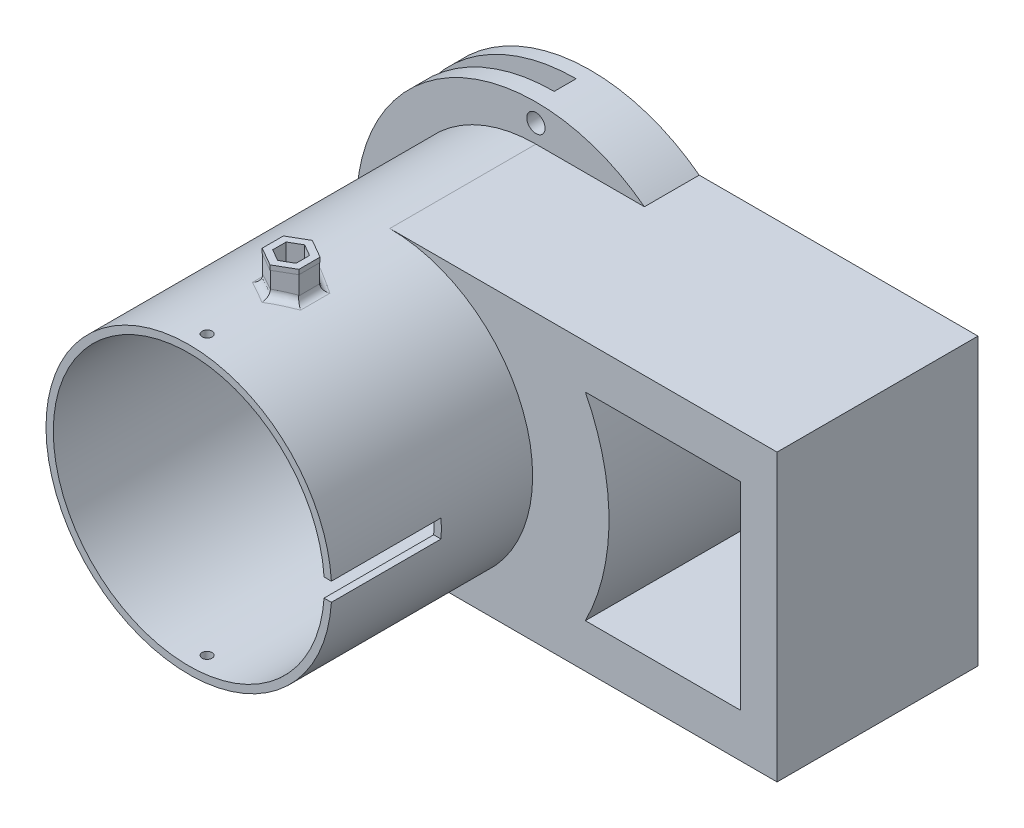
from build123d import *

# Parameters (mm, degrees)
SKETCH1_R                  = 49.657
SKETCH1_R_2                = 47.117
BOSS_EXTRUDE1_DEPTH        = 69.85
SKETCH2_R                  = 62.357
SKETCH2_R_2                = 49.657
BOSS_EXTRUDE2_DEPTH        = 19.05
F_1_4_0_2500_DOWEL_HOLE1_D = 6.35
SKETCH10_W                 = 38.1
SKETCH10_H                 = 6.35
CUT_EXTRUDE1_DEPTH         = 63.357
SKETCH12_R                 = 3.175
CUT_EXTRUDE3_DEPTH         = 63.357
CUT_EXTRUDE4_REACH         = 64.357
SKETCH14_R                 = 3.429
SKETCH14_R_2               = 3.175
CUT_EXTRUDE5_REACH         = 64.357
SKETCH15_R                 = 1.905
BOSS_EXTRUDE4_START        = 49.022
BOSS_EXTRUDE4_DEPTH        = 8.89
FILLET3_R                  = 2.54
BOSS_EXTRUDE5_DEPTH        = 1.6256
SKETCH18_W                 = 134.62
SKETCH18_H                 = 2.54
BOSS_EXTRUDE6_DEPTH        = 69.85
CUT_EXTRUDE6_START         = -5.08
SKETCH20_R                 = 59.5376
CUT_EXTRUDE6_DEPTH         = 7.62
CUT_EXTRUDE7_REACH         = 64.357
SKETCH21_W                 = 7.62
SKETCH21_H                 = 124.968
BOSS_EXTRUDE7_DEPTH        = 50.8
BOSS_EXTRUDE8_DEPTH        = 69.85


with BuildPart() as part:
    # Sketch1 → Boss-Extrude1 (new body, symmetric)
    with BuildSketch(Plane.XY):
        Circle(SKETCH1_R)
        Circle(SKETCH1_R_2, mode=Mode.SUBTRACT)
    extrude(amount=BOSS_EXTRUDE1_DEPTH, both=True)

    # Sketch2 → Boss-Extrude2 (add)
    with BuildSketch(Plane(origin=(0, 0, -69.85), x_dir=(-1, 0, 0), z_dir=(0, 0, -1))):
        Circle(SKETCH2_R)
        Circle(SKETCH2_R_2, mode=Mode.SUBTRACT)
    extrude(amount=-BOSS_EXTRUDE2_DEPTH)

    # Sketch5 → #8-32 Tapped Hole1 (revolve, cut)
    with BuildSketch(Plane(origin=(0, 0, 63.5), x_dir=(0, 0, -1), z_dir=(1, 0, 0))):
        Polygon((0, 0), (0, 62.357), (1.7272, 62.357), (1.7272, 0.9906), (2.7178, 0), align=None)
    f_8_32_tapped_hole1 = revolve(axis=Axis((0, -6.35, 63.5), (0, 1, 0)), mode=Mode.SUBTRACT)

    # Mirror1: #8-32 Tapped Hole1 across plane
    add(f_8_32_tapped_hole1.mirror(Plane.ZX), mode=Mode.SUBTRACT)

    # 1/4 (0.2500) Dowel Hole1 (through all)
    with Locations(Plane.XY.offset(-50.8)):
        with Locations((-56.007, 0), (0, 56.007), (56.007, 0), (0, -56.007)):
            Hole(F_1_4_0_2500_DOWEL_HOLE1_D / 2)

    # Sketch10 → Cut-Extrude1 (cut, through all)
    with BuildSketch(Plane(origin=(0, 0, 0), x_dir=(0, 0, -1), z_dir=(1, 0, 0))):
        with Locations((-50.8, 0)):
            Rectangle(SKETCH10_W, SKETCH10_H)
    extrude(amount=CUT_EXTRUDE1_DEPTH, mode=Mode.SUBTRACT)

    # Sketch12 → Cut-Extrude3 (cut, through all)
    with BuildSketch(Plane(origin=(0, 0, 0), x_dir=(0, 0, -1), z_dir=(1, 0, 0))):
        Circle(SKETCH12_R)
    extrude(amount=-CUT_EXTRUDE3_DEPTH, mode=Mode.SUBTRACT)

    # Sketch14 → Cut-Extrude4 (cut, up to next)
    with BuildSketch(Plane(origin=(0, 0, 0), x_dir=(0, 0, -1), z_dir=(1, 0, 0)), mode=Mode.PRIVATE) as cut_extrude4_sk1:
        Circle(SKETCH14_R)
        Circle(SKETCH14_R_2, mode=Mode.SUBTRACT)
    cut_extrude4_tool1 = extrude(cut_extrude4_sk1.sketch, amount=-CUT_EXTRUDE4_REACH, mode=Mode.PRIVATE) & part.part
    add(cut_extrude4_tool1.solids().sort_by_distance((0, 0, 3.332013))[0], mode=Mode.SUBTRACT)

    # Sketch15 → Cut-Extrude5 (cut, up to next)
    with BuildSketch(Plane(origin=(0, 0, 0), x_dir=(1, 0, 0), z_dir=(0, 1, 0)), mode=Mode.PRIVATE) as cut_extrude5_sk1:
        with Locations((0, -34.29)):
            Circle(SKETCH15_R)
    cut_extrude5_tool1 = extrude(cut_extrude5_sk1.sketch, amount=CUT_EXTRUDE5_REACH, mode=Mode.PRIVATE) & part.part
    add(cut_extrude5_tool1.solids().sort_by_distance((0, 0, 34.29))[0], mode=Mode.SUBTRACT)

    # Sketch16 → Boss-Extrude4 (add)
    with BuildSketch(Plane(origin=(0, 0, 0), x_dir=(1, 0, 0), z_dir=(0, 1, 0)).offset(BOSS_EXTRUDE4_START)):
        Polygon((-6.263704526, -30.673648506), (-6.263704526, -37.906351494), (0, -41.522702988), (6.263704526, -37.906351494), (6.263704526, -30.673648506), (0, -27.057297012), align=None)
        Polygon((0, -29.597297012), (-4.064, -31.943648506), (-4.064, -36.636351494), (0, -38.982702988), (4.064, -36.636351494), (4.064, -31.943648506), align=None, mode=Mode.SUBTRACT)
    extrude(amount=BOSS_EXTRUDE4_DEPTH)

    # Fillet3
    fillet3_edges = [part.edges().sort_by_distance(p)[0] for p in [
        (-3.136562658, 49.557841193, 28.868192307),
        (3.136562658, 49.557841193, 28.868192307),
        (6.263704526, 49.260365961, 34.29),
        (3.136562658, 49.557841193, 39.711807693),
        (-3.136562658, 49.557841193, 39.711807693),
        (-6.263704526, 49.260365961, 34.29),
    ]]
    fillet(fillet3_edges, radius=FILLET3_R)

    # Sketch17 → Boss-Extrude5 (add)
    with BuildSketch(Plane(origin=(0, 57.912, 0), x_dir=(1, 0, 0), z_dir=(0, 1, 0))):
        Polygon((-6.374687849, -37.970427746), (0, -41.650855491), (6.374687849, -37.970427746), (6.374687849, -30.609572254), (0, -26.929144509), (-6.374687849, -30.609572254), align=None)
        Polygon((-4.064, -36.636351494), (0, -38.982702988), (4.064, -36.636351494), (4.064, -31.943648506), (0, -29.597297012), (-4.064, -31.943648506), align=None, mode=Mode.SUBTRACT)
    extrude(amount=BOSS_EXTRUDE5_DEPTH)

    # Sketch18 → Boss-Extrude6 (add, through all)
    with BuildSketch(Plane.XY):
        with Locations((67.31, -48.387)):
            Rectangle(SKETCH18_W, SKETCH18_H)
        with Locations((67.31, 48.387)):
            Rectangle(SKETCH18_W, SKETCH18_H)
    extrude(amount=-BOSS_EXTRUDE6_DEPTH)

    # Sketch20 → Cut-Extrude6 (cut)
    with BuildSketch(Plane(origin=(0, 0, -69.85), x_dir=(-1, 0, 0), z_dir=(0, 0, -1)).offset(CUT_EXTRUDE6_START)):
        Circle(SKETCH20_R)
    extrude(amount=-CUT_EXTRUDE6_DEPTH, mode=Mode.SUBTRACT)

    # Sketch21 → Cut-Extrude7 (cut, up to next)
    with BuildSketch(Plane(origin=(0, 0, 0), x_dir=(0, 0, -1), z_dir=(1, 0, 0)), mode=Mode.PRIVATE) as cut_extrude7_sk1:
        with Locations((60.96, -0.127)):
            Rectangle(SKETCH21_W, SKETCH21_H)
    cut_extrude7_tool1 = extrude(cut_extrude7_sk1.sketch, amount=-CUT_EXTRUDE7_REACH, mode=Mode.PRIVATE) & part.part
    add(cut_extrude7_tool1.solids().sort_by_distance((0, -0.127, -60.96))[0], mode=Mode.SUBTRACT)

    # Sketch22 → Boss-Extrude7 (add)
    with BuildSketch(Plane.XY.offset(-50.8)):
        with BuildLine():
            Line((0, 49.657), (37.717075708, 49.657))
            ThreePointArc((37.717075708, 49.657), (62.357, 0), (37.717075708, -49.657))
            Line((37.717075708, -49.657), (0, -49.657))
            ThreePointArc((0, -49.657), (49.657, 0), (0, 49.657))
        make_face()
    extrude(amount=BOSS_EXTRUDE7_DEPTH)

    # Sketch23 → Boss-Extrude8 (add, through all)
    with BuildSketch(Plane.XY):
        with BuildLine():
            Line((40.845853645, 47.117), (134.62, 47.117))
            Line((134.62, 47.117), (134.62, -47.117))
            Line((134.62, -47.117), (40.845853645, -47.117))
            ThreePointArc((40.845853645, -47.117), (62.357, 0), (40.845853645, 47.117))
        make_face()
        with BuildLine():
            Line((67.984631432, 34.417), (121.92, 34.417))
            Line((121.92, 34.417), (121.92, -34.417))
            Line((121.92, -34.417), (67.984631432, -34.417))
            ThreePointArc((67.984631432, -34.417), (76.2, 0), (67.984631432, 34.417))
        make_face(mode=Mode.SUBTRACT)
    extrude(amount=-BOSS_EXTRUDE8_DEPTH)


solid = part.part
